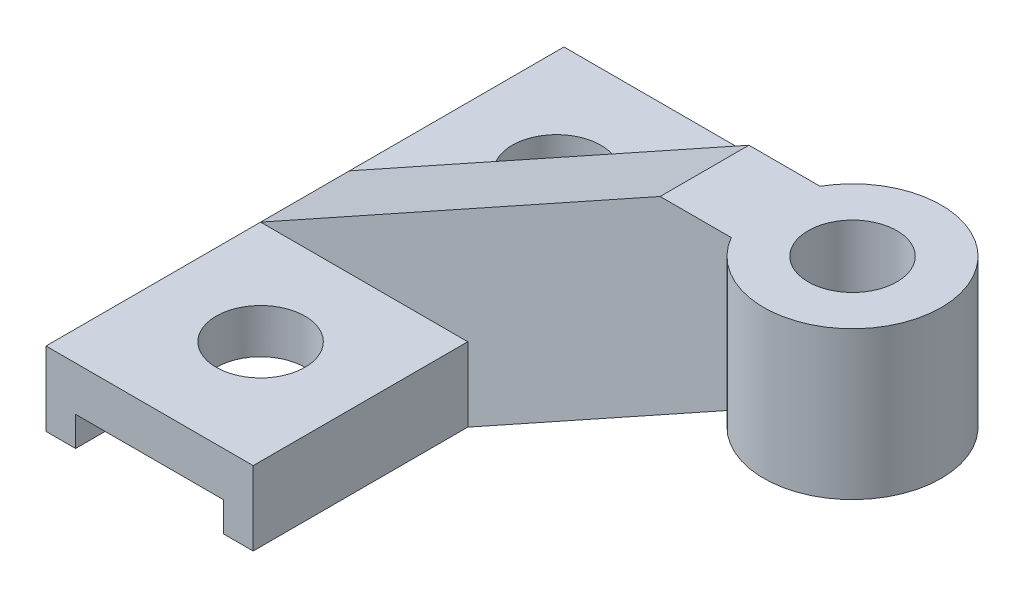
from build123d import *

# Parameters (mm, degrees)
EXTRUDE_1_DEPTH     = 17.5
EXTRUDE_2_DEPTH     = 3
EXTRUDE_START       = 5
SKETCH_5_R          = 6
SKETCH_5_R_2        = 3
EXTRUDE_3_DEPTH     = 10
SKETCH_2_R          = 3
CUT_EXTRUDE_1_DEPTH = 6


with BuildPart() as part:
    # 草圖1 → 填料-伸長1 (new body, symmetric)
    with BuildSketch(Plane.XY):
        Polygon((-7, 0), (7, 0), (7, -5), (5, -5), (5, -3), (-5, -3), (-5, -5), (-7, -5), align=None)
    extrude(amount=EXTRUDE_1_DEPTH, both=True)

    # 草圖4 → 填料-伸長2 (add, symmetric)
    with BuildSketch(Plane.XY):
        Polygon((-7, 0), (20, 15), (25, 15), (25, 5), (7, -5), (7, 0), align=None)
    extrude(amount=EXTRUDE_2_DEPTH, both=True)

    # 草圖5 → 填料-伸長3 (add)
    with BuildSketch(Plane(origin=(0, 0, 0), x_dir=(1, 0, 0), z_dir=(0, 1, 0)).offset(EXTRUDE_START)):
        with Locations((30, 0)):
            Circle(SKETCH_5_R)
        with Locations((30, 0)):
            Circle(SKETCH_5_R_2, mode=Mode.SUBTRACT)
    extrude(amount=EXTRUDE_3_DEPTH)

    # 草圖2 → 除料-伸長1 (cut, through all)
    with BuildSketch(Plane(origin=(0, 0, 0), x_dir=(1, 0, 0), z_dir=(0, 1, 0))):
        with Locations((0, -10)):
            Circle(SKETCH_2_R)
        with Locations((0, 10)):
            Circle(SKETCH_2_R)
    extrude(amount=-CUT_EXTRUDE_1_DEPTH, mode=Mode.SUBTRACT)


solid = part.part
